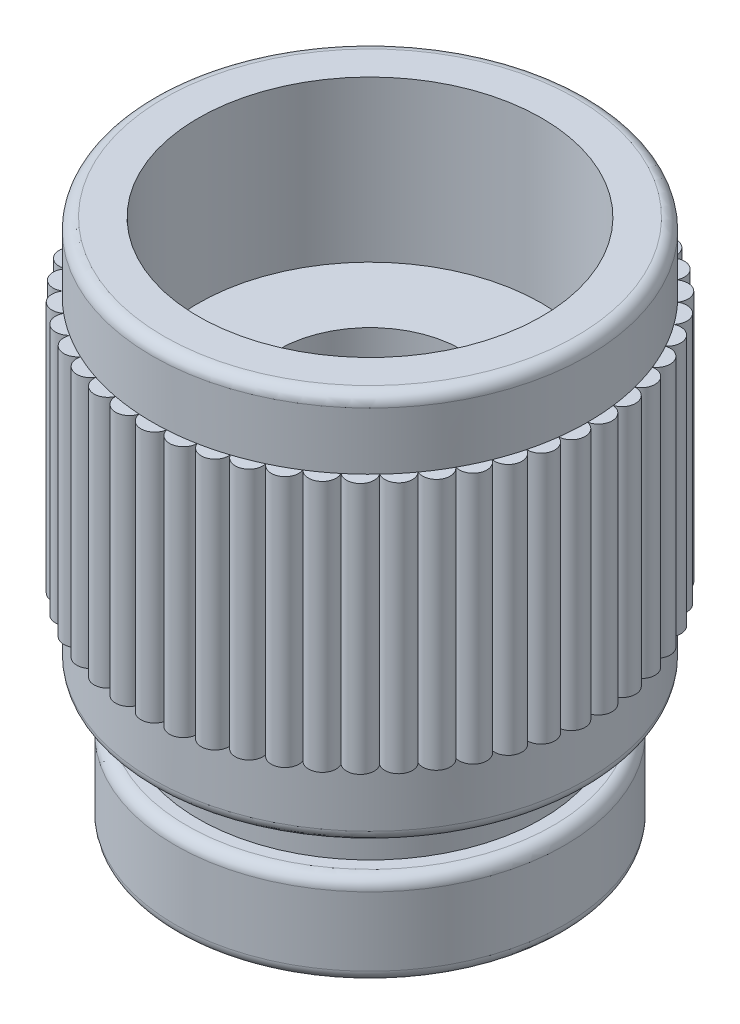
from build123d import *

# Parameters (mm, degrees)
BOSS_EXTRU_1_DEPTH = 2.75


with BuildPart() as part:
    # Esquisse1 → Révolution1 (revolve)
    with BuildSketch(Plane.XY):
        with BuildLine():
            Line((3.75, 8.5), (4.5, 8.5))
            ThreePointArc((4.5, 8.5), (4.676776695, 8.426776695), (4.75, 8.25))
            Line((4.75, 8.25), (4.75, 0.25))
            ThreePointArc((4.75, 0.25), (4.676776695, 0.073223305), (4.5, 0))
            Line((4.5, 0), (3.75, 0))
            Line((3.75, 0), (3.75, -1))
            Line((3.75, -1), (4, -1))
            ThreePointArc((4, -1), (4.176776695, -1.073223305), (4.25, -1.25))
            Line((4.25, -1.25), (4.25, -2.75))
            ThreePointArc((4.25, -2.75), (4.176776695, -2.926776695), (4, -3))
            Line((4, -3), (2.25, -3))
            ThreePointArc((2.25, -3), (2.073223305, -2.926776695), (2, -2.75))
            Line((2, -2.75), (2, 5))
            Line((2, 5), (3.75, 5))
            Line((3.75, 5), (3.75, 8.5))
        make_face()
    revolve(axis=Axis((0, 0, 0), (0, 1, 0)))

    # Esquisse2 → Boss.-Extru.1 (add, symmetric)
    with BuildSketch(Plane(origin=(0, 4.25, 0), x_dir=(1, 0, 0), z_dir=(0, 1, 0))):
        with BuildLine():
            ThreePointArc((-0.297227527, 4.740691489), (0, 5), (0.297227527, 4.740691489))
            ThreePointArc((0.297227527, 4.740691489), (0, 4.75), (-0.297227527, 4.740691489))
        make_face()
        with BuildLine():
            ThreePointArc((0.299282395, 4.740562208), (0.626666168, 4.960573507), (0.889049993, 4.666057234))
            ThreePointArc((0.889049993, 4.666057234), (0.595332859, 4.712544831), (0.299282395, 4.740562208))
        make_face()
        with BuildLine():
            ThreePointArc((0.891072454, 4.665671429), (1.243449436, 4.842915806), (1.466851609, 4.517836469))
            ThreePointArc((1.466851609, 4.517836469), (1.181276964, 4.600770015), (0.891072454, 4.665671429))
        make_face()
        with BuildLine():
            ThreePointArc((1.468809769, 4.517200224), (1.840622763, 4.648882429), (2.021520099, 4.298366723))
            ThreePointArc((2.021520099, 4.298366723), (1.748591625, 4.416438308), (1.468809769, 4.517200224))
        make_face()
        with BuildLine():
            ThreePointArc((2.023383076, 4.297490073), (2.408768371, 4.3815334), (2.54430801, 4.011109167))
            ThreePointArc((2.54430801, 4.011109167), (2.288329952, 4.16245673), (2.023383076, 4.297490073))
        make_face()
        with BuildLine():
            ThreePointArc((2.546046423, 4.010005937), (2.938926261, 4.045084972), (3.026970664, 3.660594023))
            ThreePointArc((3.026970664, 3.660594023), (2.791979948, 3.842830723), (2.546046423, 4.010005937))
        make_face()
        with BuildLine():
            ThreePointArc((3.028557097, 3.659281611), (3.42273553, 3.644843137), (3.461896181, 3.252349125))
            ThreePointArc((3.461896181, 3.252349125), (3.251598753, 3.46260098), (3.028557097, 3.659281611))
        make_face()
        with BuildLine():
            ThreePointArc((3.463305616, 3.250848229), (3.852566214, 3.187119949), (3.842225528, 2.792812738))
            ThreePointArc((3.842225528, 2.792812738), (3.659937903, 3.027763951), (3.463305616, 3.250848229))
        make_face()
        with BuildLine():
            ThreePointArc((3.843435738, 2.791147028), (4.221639628, 2.679133975), (4.161960684, 2.289232026))
            ThreePointArc((4.161960684, 2.289232026), (4.010557646, 2.545177276), (3.843435738, 2.791147028))
        make_face()
        with BuildLine():
            ThreePointArc((4.162952581, 2.287427771), (4.524135262, 2.128896458), (4.416059233, 1.749548757))
            ThreePointArc((4.416059233, 1.749548757), (4.297928499, 2.022451635), (4.162952581, 2.287427771))
        make_face()
        with BuildLine():
            ThreePointArc((4.416817176, 1.747634411), (4.755282581, 1.545084972), (4.60051389, 1.182274059))
            ThreePointArc((4.60051389, 1.182274059), (4.517518452, 1.467830723), (4.416817176, 1.747634411))
        make_face()
        with BuildLine():
            ThreePointArc((4.601025925, 1.180279813), (4.911436254, 0.936906573), (4.712415694, 0.596354193))
            ThreePointArc((4.712415694, 0.596354193), (4.665864441, 0.890061244), (4.601025925, 1.180279813))
        make_face()
        with BuildLine():
            ThreePointArc((4.712673747, 0.594311498), (4.990133642, 0.313952598), (4.749999888, 0.001029465))
            ThreePointArc((4.749999888, 0.001029465), (4.74062696, 0.298254968), (4.712673747, 0.594311498))
        make_face()
        with BuildLine():
            ThreePointArc((4.749999888, -0.001029465), (4.990133642, -0.313952598), (4.712673747, -0.594311498))
            ThreePointArc((4.712673747, -0.594311498), (4.74062696, -0.298254968), (4.749999888, -0.001029465))
        make_face()
        with BuildLine():
            ThreePointArc((4.712415694, -0.596354193), (4.911436254, -0.936906573), (4.601025925, -1.180279813))
            ThreePointArc((4.601025925, -1.180279813), (4.665864441, -0.890061244), (4.712415694, -0.596354193))
        make_face()
        with BuildLine():
            ThreePointArc((4.60051389, -1.182274059), (4.755282581, -1.545084972), (4.416817176, -1.747634411))
            ThreePointArc((4.416817176, -1.747634411), (4.517518452, -1.467830723), (4.60051389, -1.182274059))
        make_face()
        with BuildLine():
            ThreePointArc((4.416059233, -1.749548757), (4.524135262, -2.128896458), (4.162952581, -2.287427771))
            ThreePointArc((4.162952581, -2.287427771), (4.297928499, -2.022451635), (4.416059233, -1.749548757))
        make_face()
        with BuildLine():
            ThreePointArc((4.161960684, -2.289232026), (4.221639628, -2.679133975), (3.843435738, -2.791147028))
            ThreePointArc((3.843435738, -2.791147028), (4.010557646, -2.545177276), (4.161960684, -2.289232026))
        make_face()
        with BuildLine():
            ThreePointArc((3.842225528, -2.792812738), (3.852566214, -3.187119949), (3.463305616, -3.250848229))
            ThreePointArc((3.463305616, -3.250848229), (3.659937903, -3.027763951), (3.842225528, -2.792812738))
        make_face()
        with BuildLine():
            ThreePointArc((3.461896181, -3.252349125), (3.42273553, -3.644843137), (3.028557097, -3.659281611))
            ThreePointArc((3.028557097, -3.659281611), (3.251598753, -3.46260098), (3.461896181, -3.252349125))
        make_face()
        with BuildLine():
            ThreePointArc((3.026970664, -3.660594023), (2.938926261, -4.045084972), (2.546046423, -4.010005937))
            ThreePointArc((2.546046423, -4.010005937), (2.791979948, -3.842830723), (3.026970664, -3.660594023))
        make_face()
        with BuildLine():
            ThreePointArc((2.54430801, -4.011109167), (2.408768371, -4.3815334), (2.023383076, -4.297490073))
            ThreePointArc((2.023383076, -4.297490073), (2.288329952, -4.16245673), (2.54430801, -4.011109167))
        make_face()
        with BuildLine():
            ThreePointArc((2.021520099, -4.298366723), (1.840622763, -4.648882429), (1.468809769, -4.517200224))
            ThreePointArc((1.468809769, -4.517200224), (1.748591625, -4.416438308), (2.021520099, -4.298366723))
        make_face()
        with BuildLine():
            ThreePointArc((1.466851609, -4.517836469), (1.243449436, -4.842915806), (0.891072454, -4.665671429))
            ThreePointArc((0.891072454, -4.665671429), (1.181276964, -4.600770015), (1.466851609, -4.517836469))
        make_face()
        with BuildLine():
            ThreePointArc((0.889049993, -4.666057234), (0.626666168, -4.960573507), (0.299282395, -4.740562208))
            ThreePointArc((0.299282395, -4.740562208), (0.595332859, -4.712544831), (0.889049993, -4.666057234))
        make_face()
        with BuildLine():
            ThreePointArc((0.297227527, -4.740691489), (0, -5), (-0.297227527, -4.740691489))
            ThreePointArc((-0.297227527, -4.740691489), (0, -4.75), (0.297227527, -4.740691489))
        make_face()
        with BuildLine():
            ThreePointArc((-0.299282395, -4.740562208), (-0.626666168, -4.960573507), (-0.889049993, -4.666057234))
            ThreePointArc((-0.889049993, -4.666057234), (-0.595332859, -4.712544831), (-0.299282395, -4.740562208))
        make_face()
        with BuildLine():
            ThreePointArc((-0.891072454, -4.665671429), (-1.243449436, -4.842915806), (-1.466851609, -4.517836469))
            ThreePointArc((-1.466851609, -4.517836469), (-1.181276964, -4.600770015), (-0.891072454, -4.665671429))
        make_face()
        with BuildLine():
            ThreePointArc((-1.468809769, -4.517200224), (-1.840622763, -4.648882429), (-2.021520099, -4.298366723))
            ThreePointArc((-2.021520099, -4.298366723), (-1.748591625, -4.416438308), (-1.468809769, -4.517200224))
        make_face()
        with BuildLine():
            ThreePointArc((-2.023383076, -4.297490073), (-2.408768371, -4.3815334), (-2.54430801, -4.011109167))
            ThreePointArc((-2.54430801, -4.011109167), (-2.288329952, -4.16245673), (-2.023383076, -4.297490073))
        make_face()
        with BuildLine():
            ThreePointArc((-2.546046423, -4.010005937), (-2.938926261, -4.045084972), (-3.026970664, -3.660594023))
            ThreePointArc((-3.026970664, -3.660594023), (-2.791979948, -3.842830723), (-2.546046423, -4.010005937))
        make_face()
        with BuildLine():
            ThreePointArc((-3.028557097, -3.659281611), (-3.42273553, -3.644843137), (-3.461896181, -3.252349125))
            ThreePointArc((-3.461896181, -3.252349125), (-3.251598753, -3.46260098), (-3.028557097, -3.659281611))
        make_face()
        with BuildLine():
            ThreePointArc((-3.463305616, -3.250848229), (-3.852566214, -3.187119949), (-3.842225528, -2.792812738))
            ThreePointArc((-3.842225528, -2.792812738), (-3.659937903, -3.027763951), (-3.463305616, -3.250848229))
        make_face()
        with BuildLine():
            ThreePointArc((-3.843435738, -2.791147028), (-4.221639628, -2.679133975), (-4.161960684, -2.289232026))
            ThreePointArc((-4.161960684, -2.289232026), (-4.010557646, -2.545177276), (-3.843435738, -2.791147028))
        make_face()
        with BuildLine():
            ThreePointArc((-4.162952581, -2.287427771), (-4.524135262, -2.128896458), (-4.416059233, -1.749548757))
            ThreePointArc((-4.416059233, -1.749548757), (-4.297928499, -2.022451635), (-4.162952581, -2.287427771))
        make_face()
        with BuildLine():
            ThreePointArc((-4.416817176, -1.747634411), (-4.755282581, -1.545084972), (-4.60051389, -1.182274059))
            ThreePointArc((-4.60051389, -1.182274059), (-4.517518452, -1.467830723), (-4.416817176, -1.747634411))
        make_face()
        with BuildLine():
            ThreePointArc((-4.601025925, -1.180279813), (-4.911436254, -0.936906573), (-4.712415694, -0.596354193))
            ThreePointArc((-4.712415694, -0.596354193), (-4.665864441, -0.890061244), (-4.601025925, -1.180279813))
        make_face()
        with BuildLine():
            ThreePointArc((-4.712673747, -0.594311498), (-4.990133642, -0.313952598), (-4.749999888, -0.001029465))
            ThreePointArc((-4.749999888, -0.001029465), (-4.74062696, -0.298254968), (-4.712673747, -0.594311498))
        make_face()
        with BuildLine():
            ThreePointArc((-4.749999888, 0.001029465), (-4.990133642, 0.313952598), (-4.712673747, 0.594311498))
            ThreePointArc((-4.712673747, 0.594311498), (-4.74062696, 0.298254968), (-4.749999888, 0.001029465))
        make_face()
        with BuildLine():
            ThreePointArc((-4.712415694, 0.596354193), (-4.911436254, 0.936906573), (-4.601025925, 1.180279813))
            ThreePointArc((-4.601025925, 1.180279813), (-4.665864441, 0.890061244), (-4.712415694, 0.596354193))
        make_face()
        with BuildLine():
            ThreePointArc((-4.60051389, 1.182274059), (-4.755282581, 1.545084972), (-4.416817176, 1.747634411))
            ThreePointArc((-4.416817176, 1.747634411), (-4.517518452, 1.467830723), (-4.60051389, 1.182274059))
        make_face()
        with BuildLine():
            ThreePointArc((-4.416059233, 1.749548757), (-4.524135262, 2.128896458), (-4.162952581, 2.287427771))
            ThreePointArc((-4.162952581, 2.287427771), (-4.297928499, 2.022451635), (-4.416059233, 1.749548757))
        make_face()
        with BuildLine():
            ThreePointArc((-4.161960684, 2.289232026), (-4.221639628, 2.679133975), (-3.843435738, 2.791147028))
            ThreePointArc((-3.843435738, 2.791147028), (-4.010557646, 2.545177276), (-4.161960684, 2.289232026))
        make_face()
        with BuildLine():
            ThreePointArc((-3.842225528, 2.792812738), (-3.852566214, 3.187119949), (-3.463305616, 3.250848229))
            ThreePointArc((-3.463305616, 3.250848229), (-3.659937903, 3.027763951), (-3.842225528, 2.792812738))
        make_face()
        with BuildLine():
            ThreePointArc((-3.461896181, 3.252349125), (-3.42273553, 3.644843137), (-3.028557097, 3.659281611))
            ThreePointArc((-3.028557097, 3.659281611), (-3.251598753, 3.46260098), (-3.461896181, 3.252349125))
        make_face()
        with BuildLine():
            ThreePointArc((-3.026970664, 3.660594023), (-2.938926261, 4.045084972), (-2.546046423, 4.010005937))
            ThreePointArc((-2.546046423, 4.010005937), (-2.791979948, 3.842830723), (-3.026970664, 3.660594023))
        make_face()
        with BuildLine():
            ThreePointArc((-2.54430801, 4.011109167), (-2.408768371, 4.3815334), (-2.023383076, 4.297490073))
            ThreePointArc((-2.023383076, 4.297490073), (-2.288329952, 4.16245673), (-2.54430801, 4.011109167))
        make_face()
        with BuildLine():
            ThreePointArc((-2.021520099, 4.298366723), (-1.840622763, 4.648882429), (-1.468809769, 4.517200224))
            ThreePointArc((-1.468809769, 4.517200224), (-1.748591625, 4.416438308), (-2.021520099, 4.298366723))
        make_face()
        with BuildLine():
            ThreePointArc((-1.466851609, 4.517836469), (-1.243449436, 4.842915806), (-0.891072454, 4.665671429))
            ThreePointArc((-0.891072454, 4.665671429), (-1.181276964, 4.600770015), (-1.466851609, 4.517836469))
        make_face()
        with BuildLine():
            ThreePointArc((-0.889049993, 4.666057234), (-0.626666168, 4.960573507), (-0.299282395, 4.740562208))
            ThreePointArc((-0.299282395, 4.740562208), (-0.595332859, 4.712544831), (-0.889049993, 4.666057234))
        make_face()
    extrude(amount=BOSS_EXTRU_1_DEPTH, both=True)


solid = part.part
